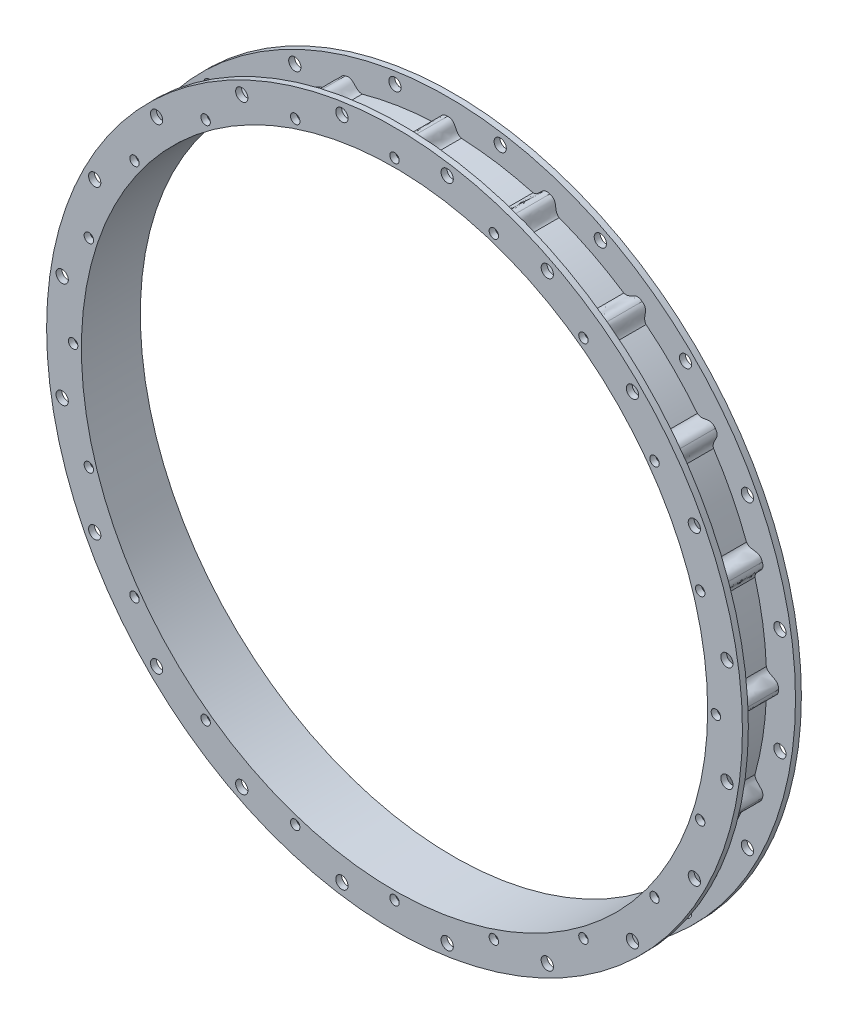
from build123d import *

# Parameters (mm, degrees)
SKETCH2_R           = 187.3885
SKETCH2_R_2         = 168.656
BOSS_EXTRUDE1_DEPTH = 3.175
SKETCH3_R           = 171.831
SKETCH3_R_2         = 168.656
BOSS_EXTRUDE2_DEPTH = 25.4
SKETCH4_R           = 187.3885
SKETCH4_R_2         = 168.656
BOSS_EXTRUDE3_DEPTH = 3.175
SKETCH5_R           = 1.27
BOSS_EXTRUDE4_DEPTH = 30.48
SKETCH6_R           = 2.54
CUT_EXTRUDE3_DEPTH  = 3.175
SKETCH7_R           = 3.302
CUT_EXTRUDE4_DEPTH  = 32.75


with BuildPart() as part:
    # Sketch2 → Boss-Extrude1 (new body)
    with BuildSketch(Plane.XY):
        Circle(SKETCH2_R)
        Circle(SKETCH2_R_2, mode=Mode.SUBTRACT)
    extrude(amount=BOSS_EXTRUDE1_DEPTH)

    # Sketch3 → Boss-Extrude2 (add)
    with BuildSketch(Plane.XY.offset(3.175)):
        Circle(SKETCH3_R)
        Circle(SKETCH3_R_2, mode=Mode.SUBTRACT)
    extrude(amount=BOSS_EXTRUDE2_DEPTH)

    # Sketch4 → Boss-Extrude3 (add)
    with BuildSketch(Plane.XY.offset(28.575)):
        Circle(SKETCH4_R)
        Circle(SKETCH4_R_2, mode=Mode.SUBTRACT)
    extrude(amount=BOSS_EXTRUDE3_DEPTH)

    # Sketch5 → Boss-Extrude4 (add)
    with BuildSketch(Plane.XY.offset(31.75)):
        with BuildLine():
            Line((-7.405015197, 171.671367184), (7.405015197, 171.671367184))
            add(Edge.make_bspline(
                [(0, 178.234154253), (4.961940314, 178.4344709), (3.628279784, 172.828030111), (7.405015197, 171.671367184)],
                knots=[0, 0, 0, 0, 1, 1, 1, 1], degree=3))
            add(Edge.make_bspline(
                [(0, 178.234154253), (-4.961940314, 178.4344709), (-3.628279784, 172.828030111), (-7.405015197, 171.671367184)],
                knots=[0, 0, 0, 0, 1, 1, 1, 1], degree=3))
        make_face()
        with Locations((0, 173.101)):
            Circle(SKETCH5_R, mode=Mode.SUBTRACT)
        with BuildLine():
            Line((46.006781951, 165.557447961), (60.091957864, 160.980896883))
            add(Edge.make_bspline(
                [(55.077382642, 169.510753828), (59.858369559, 168.167942399), (56.85749754, 163.248024122), (60.091957864, 160.980896883)],
                knots=[0, 0, 0, 0, 1, 1, 1, 1], degree=3))
            add(Edge.make_bspline(
                [(55.077382642, 169.510753828), (50.420198222, 171.234590163), (49.956099277, 165.490424349), (46.006781951, 165.557447961)],
                knots=[0, 0, 0, 0, 1, 1, 1, 1], degree=3))
        make_face()
        with Locations((53.491150743, 164.628834027)):
            Circle(SKETCH5_R, mode=Mode.SUBTRACT)
        with BuildLine():
            Line((94.915114734, 143.237612225), (106.89668101, 134.532494774))
            add(Edge.make_bspline(
                [(104.763407324, 144.194459768), (108.895444535, 141.439964002), (104.521107288, 137.688164116), (106.89668101, 134.532494774)],
                knots=[0, 0, 0, 0, 1, 1, 1, 1], degree=3))
            add(Edge.make_bspline(
                [(104.763407324, 144.194459768), (100.866856457, 147.27307468), (98.650427276, 141.953462812), (94.915114734, 143.237612225)],
                knots=[0, 0, 0, 0, 1, 1, 1, 1], degree=3))
        make_face()
        with Locations((101.746214957, 140.041650743)):
            Circle(SKETCH5_R, mode=Mode.SUBTRACT)
        with BuildLine():
            Line((134.532494774, 106.89668101), (143.237612225, 94.915114734))
            add(Edge.make_bspline(
                [(144.194459768, 104.763407324), (147.27307468, 100.866856457), (141.953462812, 98.650427276), (143.237612225, 94.915114734)],
                knots=[0, 0, 0, 0, 1, 1, 1, 1], degree=3))
            add(Edge.make_bspline(
                [(144.194459768, 104.763407324), (141.439964002, 108.895444535), (137.688164116, 104.521107288), (134.532494774, 106.89668101)],
                knots=[0, 0, 0, 0, 1, 1, 1, 1], degree=3))
        make_face()
        with Locations((140.041650743, 101.746214957)):
            Circle(SKETCH5_R, mode=Mode.SUBTRACT)
        with BuildLine():
            Line((160.980896883, 60.091957864), (165.557447961, 46.006781951))
            add(Edge.make_bspline(
                [(169.510753828, 55.077382642), (171.234590163, 50.420198222), (165.490424349, 49.956099277), (165.557447961, 46.006781951)],
                knots=[0, 0, 0, 0, 1, 1, 1, 1], degree=3))
            add(Edge.make_bspline(
                [(169.510753828, 55.077382642), (168.167942399, 59.858369559), (163.248024122, 56.85749754), (160.980896883, 60.091957864)],
                knots=[0, 0, 0, 0, 1, 1, 1, 1], degree=3))
        make_face()
        with Locations((164.628834027, 53.491150743)):
            Circle(SKETCH5_R, mode=Mode.SUBTRACT)
        with BuildLine():
            Line((171.671367184, 7.405015197), (171.671367184, -7.405015197))
            add(Edge.make_bspline(
                [(178.234154253, 0), (178.4344709, -4.961940314), (172.828030111, -3.628279784), (171.671367184, -7.405015197)],
                knots=[0, 0, 0, 0, 1, 1, 1, 1], degree=3))
            add(Edge.make_bspline(
                [(178.234154253, 0), (178.4344709, 4.961940314), (172.828030111, 3.628279784), (171.671367184, 7.405015197)],
                knots=[0, 0, 0, 0, 1, 1, 1, 1], degree=3))
        make_face()
        with Locations((173.101, 0)):
            Circle(SKETCH5_R, mode=Mode.SUBTRACT)
        with BuildLine():
            Line((165.557447961, -46.006781951), (160.980896883, -60.091957864))
            add(Edge.make_bspline(
                [(169.510753828, -55.077382642), (168.167942399, -59.858369559), (163.248024122, -56.85749754), (160.980896883, -60.091957864)],
                knots=[0, 0, 0, 0, 1, 1, 1, 1], degree=3))
            add(Edge.make_bspline(
                [(169.510753828, -55.077382642), (171.234590163, -50.420198222), (165.490424349, -49.956099277), (165.557447961, -46.006781951)],
                knots=[0, 0, 0, 0, 1, 1, 1, 1], degree=3))
        make_face()
        with Locations((164.628834027, -53.491150743)):
            Circle(SKETCH5_R, mode=Mode.SUBTRACT)
        with BuildLine():
            Line((143.237612225, -94.915114734), (134.532494774, -106.89668101))
            add(Edge.make_bspline(
                [(144.194459768, -104.763407324), (141.439964002, -108.895444535), (137.688164116, -104.521107288), (134.532494774, -106.89668101)],
                knots=[0, 0, 0, 0, 1, 1, 1, 1], degree=3))
            add(Edge.make_bspline(
                [(144.194459768, -104.763407324), (147.27307468, -100.866856457), (141.953462812, -98.650427276), (143.237612225, -94.915114734)],
                knots=[0, 0, 0, 0, 1, 1, 1, 1], degree=3))
        make_face()
        with Locations((140.041650743, -101.746214957)):
            Circle(SKETCH5_R, mode=Mode.SUBTRACT)
        with BuildLine():
            Line((106.89668101, -134.532494774), (94.915114734, -143.237612225))
            add(Edge.make_bspline(
                [(104.763407324, -144.194459768), (100.866856457, -147.27307468), (98.650427276, -141.953462813), (94.915114734, -143.237612225)],
                knots=[0, 0, 0, 0, 1, 1, 1, 1], degree=3))
            add(Edge.make_bspline(
                [(104.763407324, -144.194459768), (108.895444535, -141.439964002), (104.521107288, -137.688164116), (106.89668101, -134.532494774)],
                knots=[0, 0, 0, 0, 1, 1, 1, 1], degree=3))
        make_face()
        with Locations((101.746214957, -140.041650743)):
            Circle(SKETCH5_R, mode=Mode.SUBTRACT)
        with BuildLine():
            Line((60.091957864, -160.980896883), (46.006781951, -165.557447961))
            add(Edge.make_bspline(
                [(55.077382642, -169.510753828), (50.420198222, -171.234590163), (49.956099277, -165.490424349), (46.006781951, -165.557447961)],
                knots=[0, 0, 0, 0, 1, 1, 1, 1], degree=3))
            add(Edge.make_bspline(
                [(55.077382642, -169.510753828), (59.858369559, -168.167942399), (56.85749754, -163.248024122), (60.091957864, -160.980896883)],
                knots=[0, 0, 0, 0, 1, 1, 1, 1], degree=3))
        make_face()
        with Locations((53.491150743, -164.628834027)):
            Circle(SKETCH5_R, mode=Mode.SUBTRACT)
        with BuildLine():
            Line((7.405015197, -171.671367184), (-7.405015197, -171.671367184))
            add(Edge.make_bspline(
                [(0, -178.234154253), (-4.961940314, -178.4344709), (-3.628279784, -172.828030111), (-7.405015197, -171.671367184)],
                knots=[0, 0, 0, 0, 1, 1, 1, 1], degree=3))
            add(Edge.make_bspline(
                [(0, -178.234154253), (4.961940314, -178.4344709), (3.628279784, -172.828030111), (7.405015197, -171.671367184)],
                knots=[0, 0, 0, 0, 1, 1, 1, 1], degree=3))
        make_face()
        with Locations((0, -173.101)):
            Circle(SKETCH5_R, mode=Mode.SUBTRACT)
        with BuildLine():
            Line((-46.006781951, -165.557447961), (-60.091957864, -160.980896883))
            add(Edge.make_bspline(
                [(-55.077382642, -169.510753828), (-59.858369559, -168.167942399), (-56.85749754, -163.248024122), (-60.091957864, -160.980896883)],
                knots=[0, 0, 0, 0, 1, 1, 1, 1], degree=3))
            add(Edge.make_bspline(
                [(-55.077382642, -169.510753828), (-50.420198222, -171.234590163), (-49.956099277, -165.490424349), (-46.006781951, -165.557447961)],
                knots=[0, 0, 0, 0, 1, 1, 1, 1], degree=3))
        make_face()
        with Locations((-53.491150743, -164.628834027)):
            Circle(SKETCH5_R, mode=Mode.SUBTRACT)
        with BuildLine():
            Line((-94.915114734, -143.237612225), (-106.89668101, -134.532494774))
            add(Edge.make_bspline(
                [(-104.763407324, -144.194459768), (-108.895444535, -141.439964002), (-104.521107288, -137.688164116), (-106.89668101, -134.532494774)],
                knots=[0, 0, 0, 0, 1, 1, 1, 1], degree=3))
            add(Edge.make_bspline(
                [(-104.763407324, -144.194459768), (-100.866856457, -147.27307468), (-98.650427276, -141.953462812), (-94.915114734, -143.237612225)],
                knots=[0, 0, 0, 0, 1, 1, 1, 1], degree=3))
        make_face()
        with Locations((-101.746214957, -140.041650743)):
            Circle(SKETCH5_R, mode=Mode.SUBTRACT)
        with BuildLine():
            Line((-134.532494774, -106.89668101), (-143.237612225, -94.915114734))
            add(Edge.make_bspline(
                [(-144.194459768, -104.763407324), (-147.27307468, -100.866856457), (-141.953462813, -98.650427276), (-143.237612225, -94.915114734)],
                knots=[0, 0, 0, 0, 1, 1, 1, 1], degree=3))
            add(Edge.make_bspline(
                [(-144.194459768, -104.763407324), (-141.439964001, -108.895444535), (-137.688164116, -104.521107288), (-134.532494774, -106.89668101)],
                knots=[0, 0, 0, 0, 1, 1, 1, 1], degree=3))
        make_face()
        with Locations((-140.041650743, -101.746214957)):
            Circle(SKETCH5_R, mode=Mode.SUBTRACT)
        with BuildLine():
            Line((-160.980896882, -60.091957864), (-165.557447961, -46.006781951))
            add(Edge.make_bspline(
                [(-169.510753828, -55.077382642), (-171.234590163, -50.420198222), (-165.490424349, -49.956099277), (-165.557447961, -46.006781951)],
                knots=[0, 0, 0, 0, 1, 1, 1, 1], degree=3))
            add(Edge.make_bspline(
                [(-169.510753828, -55.077382642), (-168.167942399, -59.858369559), (-163.248024122, -56.85749754), (-160.980896882, -60.091957864)],
                knots=[0, 0, 0, 0, 1, 1, 1, 1], degree=3))
        make_face()
        with Locations((-164.628834027, -53.491150743)):
            Circle(SKETCH5_R, mode=Mode.SUBTRACT)
        with BuildLine():
            Line((-171.671367184, -7.405015197), (-171.671367184, 7.405015197))
            add(Edge.make_bspline(
                [(-178.234154253, 0), (-178.4344709, 4.961940314), (-172.828030111, 3.628279784), (-171.671367184, 7.405015197)],
                knots=[0, 0, 0, 0, 1, 1, 1, 1], degree=3))
            add(Edge.make_bspline(
                [(-178.234154253, 0), (-178.4344709, -4.961940314), (-172.828030111, -3.628279784), (-171.671367184, -7.405015197)],
                knots=[0, 0, 0, 0, 1, 1, 1, 1], degree=3))
        make_face()
        with Locations((-173.101, 0)):
            Circle(SKETCH5_R, mode=Mode.SUBTRACT)
        with BuildLine():
            Line((-165.557447961, 46.006781951), (-160.980896883, 60.091957864))
            add(Edge.make_bspline(
                [(-169.510753828, 55.077382642), (-168.167942399, 59.858369559), (-163.248024122, 56.85749754), (-160.980896883, 60.091957864)],
                knots=[0, 0, 0, 0, 1, 1, 1, 1], degree=3))
            add(Edge.make_bspline(
                [(-169.510753828, 55.077382642), (-171.234590163, 50.420198222), (-165.490424349, 49.956099277), (-165.557447961, 46.006781951)],
                knots=[0, 0, 0, 0, 1, 1, 1, 1], degree=3))
        make_face()
        with Locations((-164.628834027, 53.491150743)):
            Circle(SKETCH5_R, mode=Mode.SUBTRACT)
        with BuildLine():
            Line((-143.237612225, 94.915114734), (-134.532494774, 106.89668101))
            add(Edge.make_bspline(
                [(-144.194459768, 104.763407324), (-141.439964002, 108.895444535), (-137.688164116, 104.521107288), (-134.532494774, 106.89668101)],
                knots=[0, 0, 0, 0, 1, 1, 1, 1], degree=3))
            add(Edge.make_bspline(
                [(-144.194459768, 104.763407324), (-147.27307468, 100.866856457), (-141.953462812, 98.650427276), (-143.237612225, 94.915114734)],
                knots=[0, 0, 0, 0, 1, 1, 1, 1], degree=3))
        make_face()
        with Locations((-140.041650743, 101.746214957)):
            Circle(SKETCH5_R, mode=Mode.SUBTRACT)
        with BuildLine():
            Line((-106.89668101, 134.532494774), (-94.915114734, 143.237612225))
            add(Edge.make_bspline(
                [(-104.763407324, 144.194459768), (-100.866856457, 147.27307468), (-98.650427276, 141.953462812), (-94.915114734, 143.237612225)],
                knots=[0, 0, 0, 0, 1, 1, 1, 1], degree=3))
            add(Edge.make_bspline(
                [(-104.763407324, 144.194459768), (-108.895444535, 141.439964002), (-104.521107288, 137.688164116), (-106.89668101, 134.532494774)],
                knots=[0, 0, 0, 0, 1, 1, 1, 1], degree=3))
        make_face()
        with Locations((-101.746214957, 140.041650743)):
            Circle(SKETCH5_R, mode=Mode.SUBTRACT)
        with BuildLine():
            Line((-60.091957864, 160.980896883), (-46.006781951, 165.557447961))
            add(Edge.make_bspline(
                [(-55.077382642, 169.510753828), (-50.420198222, 171.234590163), (-49.956099277, 165.490424349), (-46.006781951, 165.557447961)],
                knots=[0, 0, 0, 0, 1, 1, 1, 1], degree=3))
            add(Edge.make_bspline(
                [(-55.077382642, 169.510753828), (-59.858369559, 168.167942399), (-56.85749754, 163.248024122), (-60.091957864, 160.980896883)],
                knots=[0, 0, 0, 0, 1, 1, 1, 1], degree=3))
        make_face()
        with Locations((-53.491150743, 164.628834027)):
            Circle(SKETCH5_R, mode=Mode.SUBTRACT)
    extrude(amount=-BOSS_EXTRUDE4_DEPTH)

    # Sketch6 → Cut-Extrude3 (cut)
    with BuildSketch(Plane.XY.offset(31.75)):
        with Locations((0, 173.101)):
            Circle(SKETCH6_R)
        with Locations((53.491150743, 164.628834027)):
            Circle(SKETCH6_R)
        with Locations((101.746214957, 140.041650743)):
            Circle(SKETCH6_R)
        with Locations((140.041650743, 101.746214957)):
            Circle(SKETCH6_R)
        with Locations((164.628834027, 53.491150743)):
            Circle(SKETCH6_R)
        with Locations((173.101, 0)):
            Circle(SKETCH6_R)
        with Locations((164.628834027, -53.491150743)):
            Circle(SKETCH6_R)
        with Locations((140.041650743, -101.746214957)):
            Circle(SKETCH6_R)
        with Locations((101.746214957, -140.041650743)):
            Circle(SKETCH6_R)
        with Locations((53.491150743, -164.628834027)):
            Circle(SKETCH6_R)
        with Locations((0, -173.101)):
            Circle(SKETCH6_R)
        with Locations((-53.491150743, -164.628834027)):
            Circle(SKETCH6_R)
        with Locations((-101.746214957, -140.041650743)):
            Circle(SKETCH6_R)
        with Locations((-140.041650743, -101.746214957)):
            Circle(SKETCH6_R)
        with Locations((-164.628834027, -53.491150743)):
            Circle(SKETCH6_R)
        with Locations((-173.101, 0)):
            Circle(SKETCH6_R)
        with Locations((-164.628834027, 53.491150743)):
            Circle(SKETCH6_R)
        with Locations((-140.041650743, 101.746214957)):
            Circle(SKETCH6_R)
        with Locations((-101.746214957, 140.041650743)):
            Circle(SKETCH6_R)
        with Locations((-53.491150743, 164.628834027)):
            Circle(SKETCH6_R)
    extrude(amount=-CUT_EXTRUDE3_DEPTH, mode=Mode.SUBTRACT)

    # Sketch7 → Cut-Extrude4 (cut, through all)
    with BuildSketch(Plane.XY.offset(31.75)):
        with Locations((28.350461665, 178.997770278)):
            Circle(SKETCH7_R)
        with Locations((82.276244277, 161.476221372)):
            Circle(SKETCH7_R)
        with Locations((128.148254848, 128.148254848)):
            Circle(SKETCH7_R)
        with Locations((161.476221372, 82.276244277)):
            Circle(SKETCH7_R)
        with Locations((178.997770278, 28.350461665)):
            Circle(SKETCH7_R)
        with Locations((178.997770278, -28.350461665)):
            Circle(SKETCH7_R)
        with Locations((161.476221372, -82.276244277)):
            Circle(SKETCH7_R)
        with Locations((128.148254848, -128.148254848)):
            Circle(SKETCH7_R)
        with Locations((82.276244277, -161.476221372)):
            Circle(SKETCH7_R)
        with Locations((28.350461665, -178.997770278)):
            Circle(SKETCH7_R)
        with Locations((-28.350461665, -178.997770278)):
            Circle(SKETCH7_R)
        with Locations((-82.276244277, -161.476221372)):
            Circle(SKETCH7_R)
        with Locations((-128.148254848, -128.148254848)):
            Circle(SKETCH7_R)
        with Locations((-161.476221372, -82.276244277)):
            Circle(SKETCH7_R)
        with Locations((-178.997770278, -28.350461665)):
            Circle(SKETCH7_R)
        with Locations((-178.997770278, 28.350461665)):
            Circle(SKETCH7_R)
        with Locations((-161.476221372, 82.276244277)):
            Circle(SKETCH7_R)
        with Locations((-128.148254848, 128.148254848)):
            Circle(SKETCH7_R)
        with Locations((-82.276244277, 161.476221372)):
            Circle(SKETCH7_R)
        with Locations((-28.350461665, 178.997770278)):
            Circle(SKETCH7_R)
    extrude(amount=-CUT_EXTRUDE4_DEPTH, mode=Mode.SUBTRACT)


solid = part.part
